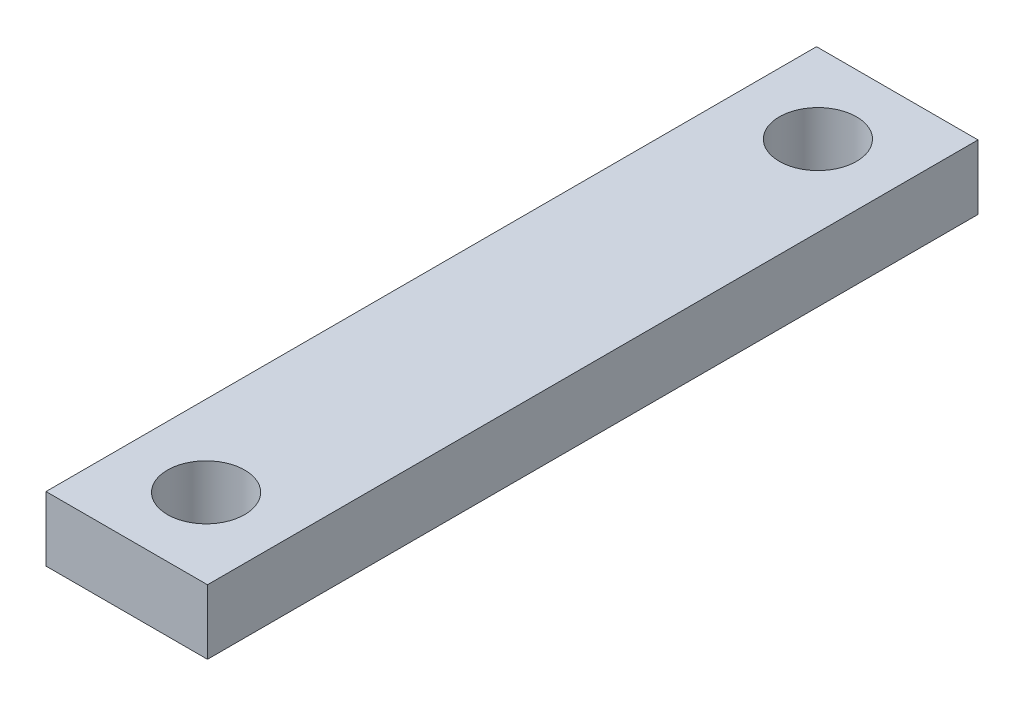
from build123d import *

# Parameters (mm, degrees)
SKETCH1_W           = 7.9375
SKETCH1_H           = 3.175
BOSS_EXTRUDE2_DEPTH = 37.875
SKETCH3_R           = 1.89865
CUT_EXTRUDE1_DEPTH  = 4.175


with BuildPart() as part:
    # Sketch1 → Boss-Extrude2 (new body)
    with BuildSketch(Plane.XY):
        with Locations((3.96875, 1.5875)):
            Rectangle(SKETCH1_W, SKETCH1_H)
    extrude(amount=BOSS_EXTRUDE2_DEPTH)

    # Sketch3 → Cut-Extrude1 (cut, through all)
    with BuildSketch(Plane(origin=(0, 3.175, 0), x_dir=(1, 0, 0), z_dir=(0, 1, 0))):
        with Locations((3.96875, -3.9)):
            Circle(SKETCH3_R)
        with Locations((3.96875, -33.975)):
            Circle(SKETCH3_R)
    extrude(amount=-CUT_EXTRUDE1_DEPTH, mode=Mode.SUBTRACT)


solid = part.part
